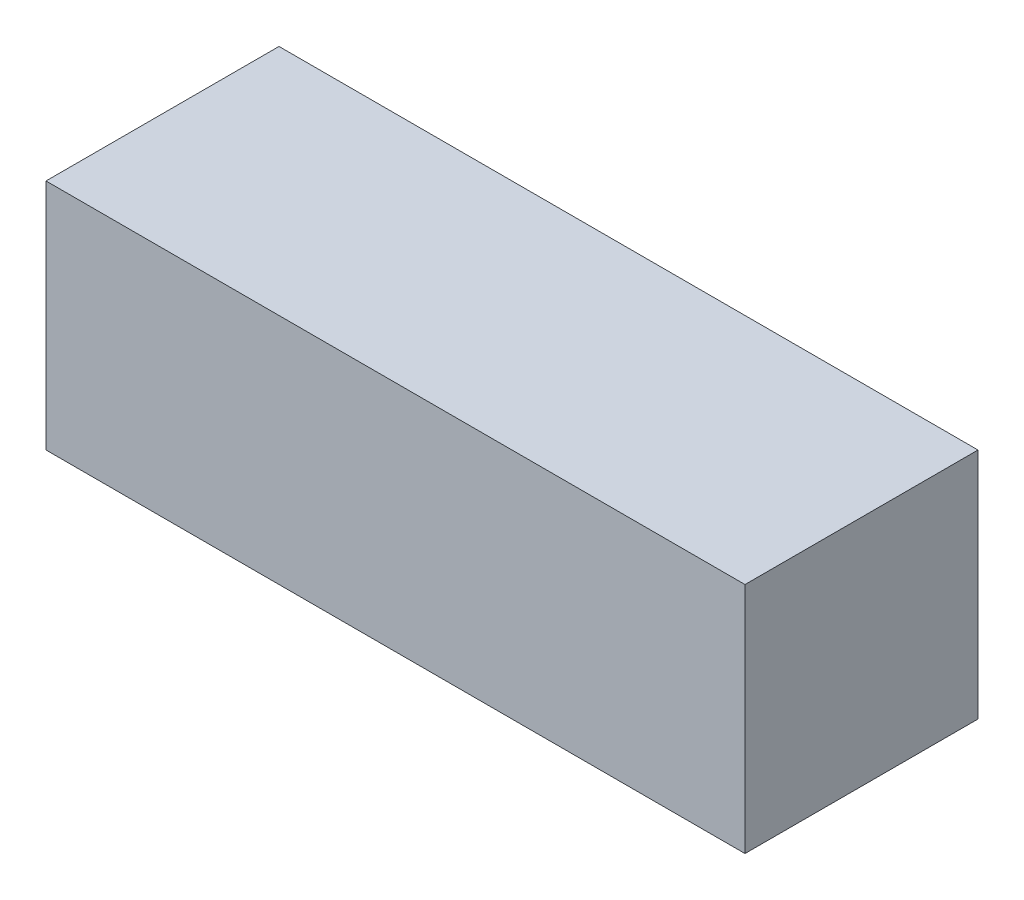
from build123d import *

# Parameters (mm, degrees)
SKETCH_1_W      = 10
SKETCH_1_H      = 10
EXTRUDE_1_DEPTH = 30


with BuildPart() as part:
    # Эскиз1 → Бобышка-Вытянуть1 (new body)
    with BuildSketch(Plane(origin=(0, 0, 0), x_dir=(0, 0, -1), z_dir=(1, 0, 0))):
        with Locations((5, 5)):
            Rectangle(SKETCH_1_W, SKETCH_1_H)
    extrude(amount=EXTRUDE_1_DEPTH)


solid = part.part
